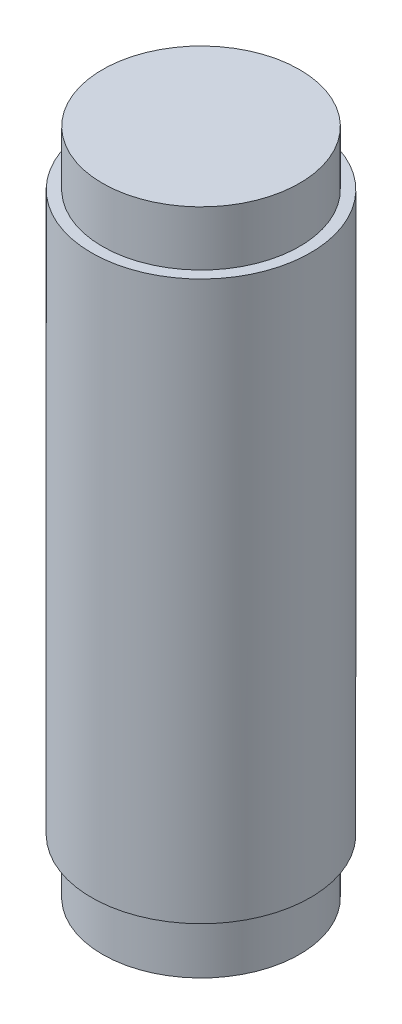
from build123d import *

# Parameters (mm, degrees)
SKETCH1_R           = 5
BOSS_EXTRUDE1_DEPTH = 30.5
SKETCH24_R          = 5
SKETCH24_R_2        = 4.5
CUT_EXTRUDE3_DEPTH  = 2.5
SKETCH25_R          = 5
SKETCH25_R_2        = 4.5
CUT_EXTRUDE4_DEPTH  = 2.5


with BuildPart() as part:
    # Sketch1 → Boss-Extrude1 (new body)
    with BuildSketch(Plane(origin=(0, 0, 0), x_dir=(1, 0, 0), z_dir=(0, 1, 0))):
        Circle(SKETCH1_R)
    extrude(amount=BOSS_EXTRUDE1_DEPTH)

    # Sketch24 → Cut-Extrude3 (cut)
    with BuildSketch(Plane(origin=(0, 0, 0), x_dir=(-1, 0, 0), z_dir=(0, -1, 0))):
        Circle(SKETCH24_R)
        Circle(SKETCH24_R_2, mode=Mode.SUBTRACT)
    extrude(amount=-CUT_EXTRUDE3_DEPTH, mode=Mode.SUBTRACT)

    # Sketch25 → Cut-Extrude4 (cut)
    with BuildSketch(Plane(origin=(0, 30.5, 0), x_dir=(1, 0, 0), z_dir=(0, 1, 0))):
        Circle(SKETCH25_R)
        Circle(SKETCH25_R_2, mode=Mode.SUBTRACT)
    extrude(amount=-CUT_EXTRUDE4_DEPTH, mode=Mode.SUBTRACT)


solid = part.part
